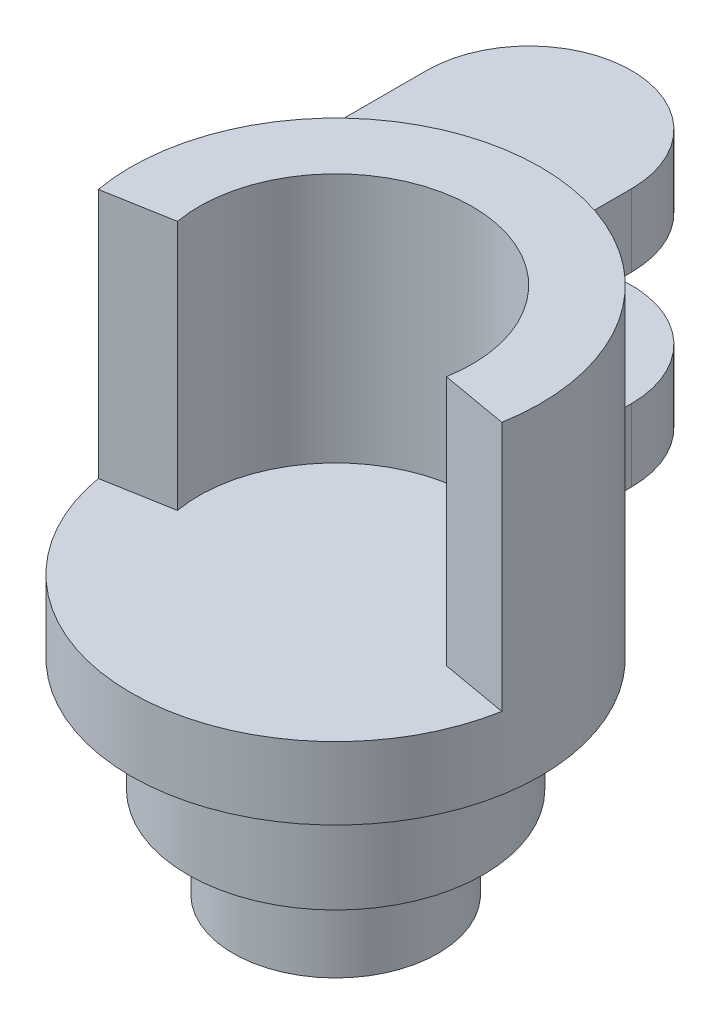
from build123d import *

# Parameters (mm, degrees)
SKETCH1_R           = 9
BOSS_EXTRUDE1_DEPTH = 3.175
BOSS_EXTRUDE2_DEPTH = 11
SKETCH4_R           = 6.5
BOSS_EXTRUDE3_DEPTH = 5
SKETCH5_R           = 4.5
BOSS_EXTRUDE4_DEPTH = 4
BOSS_EXTRUDE5_DEPTH = 3.175
BOSS_EXTRUDE6_DEPTH = 3.175


with BuildPart() as part:
    # Sketch1 → Boss-Extrude1 (new body)
    with BuildSketch(Plane(origin=(0, 0, 0), x_dir=(1, 0, 0), z_dir=(0, 1, 0))):
        Circle(SKETCH1_R)
    extrude(amount=BOSS_EXTRUDE1_DEPTH)

    # Sketch3 → Boss-Extrude2 (add)
    with BuildSketch(Plane(origin=(0, 3.175, 0), x_dir=(1, 0, 0), z_dir=(0, 1, 0))):
        with BuildLine():
            Line((-8.863269777, -1.562833599), (-5.908846518, -1.041889066))
            ThreePointArc((-5.908846518, -1.041889066), (0, 6), (5.908846518, -1.041889066))
            Line((5.908846518, -1.041889066), (8.863269777, -1.562833599))
            ThreePointArc((8.863269777, -1.562833599), (0, 9), (-8.863269777, -1.562833599))
        make_face()
    extrude(amount=BOSS_EXTRUDE2_DEPTH)

    # Sketch4 → Boss-Extrude3 (add)
    with BuildSketch(Plane.XZ):
        Circle(SKETCH4_R)
    extrude(amount=BOSS_EXTRUDE3_DEPTH)

    # Sketch5 → Boss-Extrude4 (add)
    with BuildSketch(Plane.XZ.offset(5)):
        Circle(SKETCH5_R)
    extrude(amount=BOSS_EXTRUDE4_DEPTH)

    # Sketch6 → Boss-Extrude5 (add)
    with BuildSketch(Plane(origin=(0, 0, 0), x_dir=(1, 0, 0), z_dir=(0, 1, 0))):
        with BuildLine():
            Line((-9, 0), (-9, 13))
            ThreePointArc((-9, 13), (-4.5, 17.5), (0, 13))
            Line((0, 13), (0, 9))
            ThreePointArc((0, 9), (-6.363961031, 6.363961031), (-9, 0))
        make_face()
    extrude(amount=BOSS_EXTRUDE5_DEPTH)

    # Sketch7 → Boss-Extrude6 (add)
    with BuildSketch(Plane(origin=(0, 8.174999906, 0), x_dir=(1, 0, 0), z_dir=(0, 1, 0))):
        with BuildLine():
            Line((0, 9), (0, 13))
            ThreePointArc((0, 13), (-4.5, 17.5), (-9, 13))
            Line((-9, 13), (-9, 0))
            ThreePointArc((-9, 0), (-6.363961031, 6.363961031), (0, 9))
        make_face()
    extrude(amount=BOSS_EXTRUDE6_DEPTH)


solid = part.part
